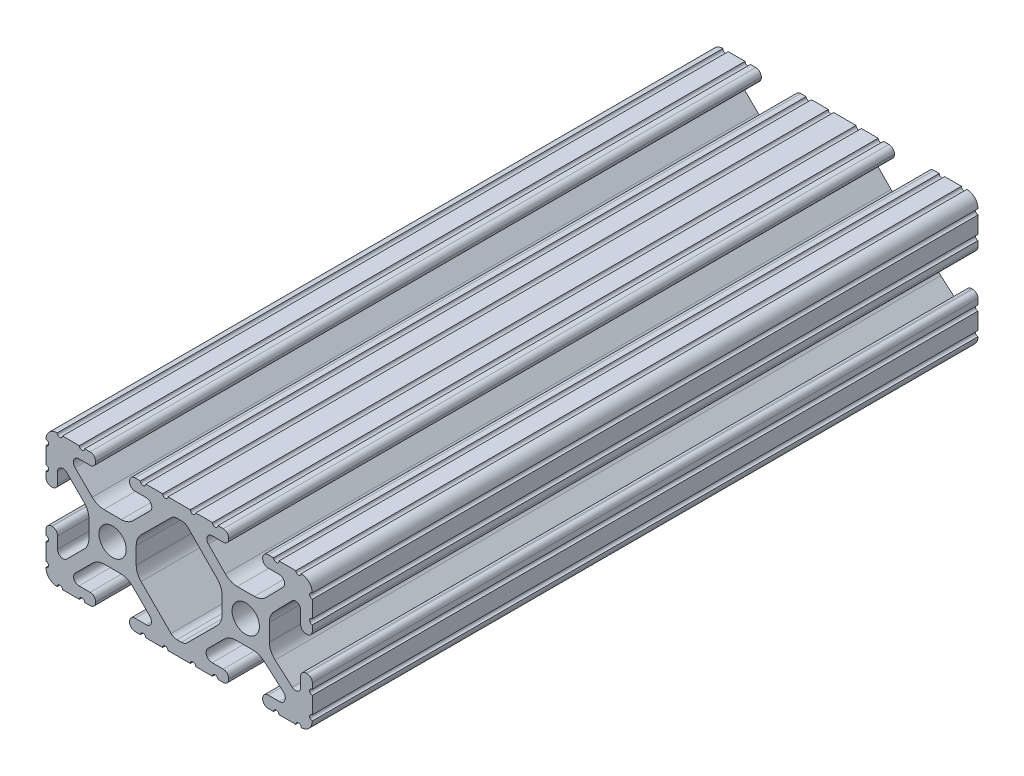
from build123d import *

# Parameters (mm, degrees)
SKETCH1_R      = 2.6035
EXTRUDE1_DEPTH = 127


with BuildPart() as part:
    # Sketch1 → Extrude1 (new body)
    with BuildSketch(Plane.XY):
        with BuildLine():
            Line((22.2504, 12.7), (19.03310265, 12.7))
            ThreePointArc((19.03310265, 12.7), (18.52510265, 12.192), (18.01710265, 12.7))
            Line((18.01710265, 12.7), (16.98745015, 12.7))
            ThreePointArc((16.98745015, 12.7), (16.245730386, 12.392769614), (15.9385, 11.65104985))
            Line((15.9385, 11.65104985), (15.9385, 11.53922))
            ThreePointArc((15.9385, 11.53922), (16.245750844, 10.797450844), (16.98752, 10.4902))
            Line((16.98752, 10.4902), (19.116384363, 10.4902))
            ThreePointArc((19.116384363, 10.4902), (20.052502933, 9.869096983), (19.844087081, 8.765172272))
            Line((19.844087081, 8.765172272), (16.618993479, 5.455112286))
            ThreePointArc((16.618993479, 5.455112286), (15.578994274, 4.745442459), (14.344932584, 4.4958))
            Line((14.344932584, 4.4958), (11.083317835, 4.4958))
            ThreePointArc((11.083317835, 4.4958), (9.854330953, 4.743306833), (8.816955189, 5.447238587))
            Line((8.816955189, 5.447238587), (5.564154119, 8.762652677))
            ThreePointArc((5.564154119, 8.762652677), (5.352591412, 9.867473037), (6.289393385, 10.4902))
            Line((6.289393385, 10.4902), (8.41248, 10.4902))
            ThreePointArc((8.41248, 10.4902), (9.154249156, 10.797450844), (9.4615, 11.53922))
            Line((9.4615, 11.53922), (9.4615, 11.65104985))
            ThreePointArc((9.4615, 11.65104985), (9.154269614, 12.392769614), (8.41254985, 12.7))
            Line((8.41254985, 12.7), (7.38288465, 12.7))
            ThreePointArc((7.38288465, 12.7), (6.87488465, 12.192), (6.36688465, 12.7))
            Line((6.36688465, 12.7), (3.14958095, 12.7))
            ThreePointArc((3.14958095, 12.7), (2.64158095, 12.192), (2.13358095, 12.7))
            Line((2.13358095, 12.7), (-2.13358095, 12.7))
            ThreePointArc((-2.13358095, 12.7), (-2.64158095, 12.192), (-3.14958095, 12.7))
            Line((-3.14958095, 12.7), (-6.36689735, 12.7))
            ThreePointArc((-6.36689735, 12.7), (-6.87489735, 12.192), (-7.38289735, 12.7))
            Line((-7.38289735, 12.7), (-8.41254985, 12.7))
            ThreePointArc((-8.41254985, 12.7), (-9.154269614, 12.392769614), (-9.4615, 11.65104985))
            Line((-9.4615, 11.65104985), (-9.4615, 11.53922))
            ThreePointArc((-9.4615, 11.53922), (-9.154249156, 10.797450844), (-8.41248, 10.4902))
            Line((-8.41248, 10.4902), (-6.283641037, 10.4902))
            ThreePointArc((-6.283641037, 10.4902), (-5.297291557, 9.829633109), (-5.532576693, 8.666071843))
            Line((-5.532576693, 8.666071843), (-8.809985098, 5.416263103))
            ThreePointArc((-8.809985098, 5.416263103), (-9.836720513, 4.734920264), (-11.045536121, 4.4958))
            Line((-11.045536121, 4.4958), (-14.354463879, 4.4958))
            ThreePointArc((-14.354463879, 4.4958), (-15.563279487, 4.734920264), (-16.590014902, 5.416263103))
            Line((-16.590014902, 5.416263103), (-19.867423307, 8.666071843))
            ThreePointArc((-19.867423307, 8.666071843), (-20.102708443, 9.829633109), (-19.116358963, 10.4902))
            Line((-19.116358963, 10.4902), (-16.98752, 10.4902))
            ThreePointArc((-16.98752, 10.4902), (-16.245750844, 10.797450844), (-15.9385, 11.53922))
            Line((-15.9385, 11.53922), (-15.9385, 11.65104985))
            ThreePointArc((-15.9385, 11.65104985), (-16.245730386, 12.392769614), (-16.98745015, 12.7))
            Line((-16.98745015, 12.7), (-18.01711535, 12.7))
            ThreePointArc((-18.01711535, 12.7), (-18.52511535, 12.192), (-19.03311535, 12.7))
            Line((-19.03311535, 12.7), (-22.2504, 12.7))
            ThreePointArc((-22.2504, 12.7), (-22.758323491, 12.192000006), (-23.266399977, 12.699846982))
            ThreePointArc((-23.266399977, 12.699846982), (-24.782522516, 12.082522516), (-25.399846982, 10.566399977))
            ThreePointArc((-25.399846982, 10.566399977), (-24.892000006, 10.058323491), (-25.4, 9.5504))
            Line((-25.4, 9.5504), (-25.4, 6.3330836))
            ThreePointArc((-25.4, 6.3330836), (-24.892, 5.8250836), (-25.4, 5.3170836))
            Line((-25.4, 5.3170836), (-25.4, 4.237520184))
            ThreePointArc((-25.4, 4.237520184), (-25.107393763, 3.531106237), (-24.400979816, 3.2385))
            Line((-24.400979816, 3.2385), (-24.23922, 3.2385))
            ThreePointArc((-24.23922, 3.2385), (-23.497450844, 3.545750844), (-23.1902, 4.28752))
            Line((-23.1902, 4.28752), (-23.1902, 6.334741132))
            ThreePointArc((-23.1902, 6.334741132), (-22.556026952, 7.286023527), (-21.434002553, 7.066535717))
            Line((-21.434002553, 7.066535717), (-18.147950853, 3.808156468))
            ThreePointArc((-18.147950853, 3.808156468), (-17.452759693, 2.774838327), (-17.208501877, 1.553619571))
            Line((-17.208501877, 1.553619571), (-17.208501877, -1.695179196))
            ThreePointArc((-17.208501877, -1.695179196), (-17.450738657, -2.911536421), (-18.140486065, -3.942289578))
            Line((-18.140486065, -3.942289578), (-21.431579576, -7.227386226))
            ThreePointArc((-21.431579576, -7.227386226), (-22.55444896, -7.449940594), (-23.1902, -6.498002195))
            Line((-23.1902, -6.498002195), (-23.1902, -4.28752))
            ThreePointArc((-23.1902, -4.28752), (-23.497450844, -3.545750844), (-24.23922, -3.2385))
            Line((-24.23922, -3.2385), (-24.35098, -3.2385))
            ThreePointArc((-24.35098, -3.2385), (-25.092749156, -3.545750844), (-25.4, -4.28752))
            Line((-25.4, -4.28752), (-25.4, -5.3171344))
            ThreePointArc((-25.4, -5.3171344), (-24.892, -5.8251344), (-25.4, -6.3331344))
            Line((-25.4, -6.3331344), (-25.4, -9.5504))
            ThreePointArc((-25.4, -9.5504), (-24.892000006, -10.058323491), (-25.399846982, -10.566399977))
            ThreePointArc((-25.399846982, -10.566399977), (-24.782522516, -12.082522516), (-23.266399977, -12.699846982))
            ThreePointArc((-23.266399977, -12.699846982), (-22.758323491, -12.192000006), (-22.2504, -12.7))
            Line((-22.2504, -12.7), (-19.03308995, -12.7))
            ThreePointArc((-19.03308995, -12.7), (-18.52508995, -12.192), (-18.01708995, -12.7))
            Line((-18.01708995, -12.7), (-16.9874692, -12.7))
            ThreePointArc((-16.9874692, -12.7), (-16.245700044, -12.392749156), (-15.9384492, -11.65098))
            Line((-15.9384492, -11.65098), (-15.9384492, -11.53922))
            ThreePointArc((-15.9384492, -11.53922), (-16.245700044, -10.797450844), (-16.9874692, -10.4902))
            Line((-16.9874692, -10.4902), (-19.116358963, -10.4902))
            ThreePointArc((-19.116358963, -10.4902), (-20.055197748, -9.862578342), (-19.834124023, -8.755124678))
            Line((-19.834124023, -8.755124678), (-16.49660751, -5.423689618))
            ThreePointArc((-16.49660751, -5.423689618), (-15.467274017, -4.736928798), (-14.253591699, -4.4958))
            Line((-14.253591699, -4.4958), (-11.146408301, -4.4958))
            ThreePointArc((-11.146408301, -4.4958), (-9.932725983, -4.736928798), (-8.90339249, -5.423689618))
            Line((-8.90339249, -5.423689618), (-5.565875977, -8.755124678))
            ThreePointArc((-5.565875977, -8.755124678), (-5.344802252, -9.862578342), (-6.283641037, -10.4902))
            Line((-6.283641037, -10.4902), (-8.4125308, -10.4902))
            ThreePointArc((-8.4125308, -10.4902), (-9.154299956, -10.797450844), (-9.4615508, -11.53922))
            Line((-9.4615508, -11.53922), (-9.4615508, -11.65098))
            ThreePointArc((-9.4615508, -11.65098), (-9.154299956, -12.392749156), (-8.4125308, -12.7))
            Line((-8.4125308, -12.7), (-7.38287195, -12.7))
            ThreePointArc((-7.38287195, -12.7), (-6.87487195, -12.192), (-6.36687195, -12.7))
            Line((-6.36687195, -12.7), (-3.14960635, -12.7))
            ThreePointArc((-3.14960635, -12.7), (-2.64160635, -12.192), (-2.13360635, -12.7))
            Line((-2.13360635, -12.7), (2.13360635, -12.7))
            ThreePointArc((2.13360635, -12.7), (2.64159365, -12.1920127), (3.14958095, -12.7))
            Line((3.14958095, -12.7), (6.36691005, -12.7))
            ThreePointArc((6.36691005, -12.7), (6.87491005, -12.192), (7.38291005, -12.7))
            Line((7.38291005, -12.7), (8.4125308, -12.7))
            ThreePointArc((8.4125308, -12.7), (9.154299956, -12.392749156), (9.4615508, -11.65098))
            Line((9.4615508, -11.65098), (9.4615508, -11.53922))
            ThreePointArc((9.4615508, -11.53922), (9.154299956, -10.797450844), (8.4125308, -10.4902))
            Line((8.4125308, -10.4902), (6.289393385, -10.4902))
            ThreePointArc((6.289393385, -10.4902), (5.231590322, -9.783049717), (5.480677245, -8.535265862))
            Line((5.480677245, -8.535265862), (8.597933595, -5.423689618))
            ThreePointArc((8.597933595, -5.423689618), (9.627267088, -4.736928798), (10.840949406, -4.4958))
            Line((10.840949406, -4.4958), (14.102564155, -4.4958))
            ThreePointArc((14.102564155, -4.4958), (15.215927525, -4.697410182), (16.187895372, -5.276636531))
            Line((16.187895372, -5.276636531), (19.868247549, -8.482246082))
            ThreePointArc((19.868247549, -8.482246082), (20.188435806, -9.746879864), (19.116384363, -10.4902))
            Line((19.116384363, -10.4902), (16.9874692, -10.4902))
            ThreePointArc((16.9874692, -10.4902), (16.245700044, -10.797450844), (15.9384492, -11.53922))
            Line((15.9384492, -11.53922), (15.9384492, -11.65098))
            ThreePointArc((15.9384492, -11.65098), (16.245700044, -12.392749156), (16.9874692, -12.7))
            Line((16.9874692, -12.7), (18.01710265, -12.7))
            ThreePointArc((18.01710265, -12.7), (18.52510265, -12.192), (19.03310265, -12.7))
            Line((19.03310265, -12.7), (22.2504, -12.7))
            ThreePointArc((22.2504, -12.7), (22.758323491, -12.192000006), (23.266399977, -12.699846982))
            ThreePointArc((23.266399977, -12.699846982), (24.782522516, -12.082522516), (25.399846982, -10.566399977))
            ThreePointArc((25.399846982, -10.566399977), (24.892000006, -10.058323492), (25.4, -9.550400001))
            Line((25.4, -9.550400001), (25.4, -6.333083592))
            ThreePointArc((25.4, -6.333083592), (24.892000001, -5.825083593), (25.4, -5.317083593))
            Line((25.4, -5.317083593), (25.4, -4.237520184))
            ThreePointArc((25.4, -4.237520184), (25.107393763, -3.531106237), (24.400979816, -3.2385))
            Line((24.400979816, -3.2385), (24.189220184, -3.2385))
            ThreePointArc((24.189220184, -3.2385), (23.482806237, -3.531106237), (23.1902, -4.237520184))
            Line((23.1902, -4.237520184), (23.1902, -6.155876159))
            ThreePointArc((23.1902, -6.155876159), (22.62232736, -7.038258539), (21.583974541, -6.886926384))
            Line((21.583974541, -6.886926384), (18.29817066, -4.024970844))
            ThreePointArc((18.29817066, -4.024970844), (17.493730985, -2.946044689), (17.208501877, -1.630807374))
            Line((17.208501877, -1.630807374), (17.208501877, 1.630807374))
            ThreePointArc((17.208501877, 1.630807374), (17.442348332, 2.82673414), (18.109440981, 3.846495088))
            Line((18.109440981, 3.846495088), (21.526346532, 7.353420386))
            ThreePointArc((21.526346532, 7.353420386), (22.585896263, 7.574939077), (23.1902, 6.676867167))
            Line((23.1902, 6.676867167), (23.1902, 4.237520184))
            ThreePointArc((23.1902, 4.237520184), (23.482806237, 3.531106237), (24.189220184, 3.2385))
            Line((24.189220184, 3.2385), (24.400979816, 3.2385))
            ThreePointArc((24.400979816, 3.2385), (25.107393763, 3.531106237), (25.4, 4.237520184))
            Line((25.4, 4.237520184), (25.4, 5.3170836))
            ThreePointArc((25.4, 5.3170836), (24.891949193, 5.825134407), (25.4, 6.333185215))
            Line((25.4, 6.333185215), (25.4, 9.550400015))
            ThreePointArc((25.4, 9.550400015), (24.892000013, 10.058323498), (25.399846982, 10.566399977))
            ThreePointArc((25.399846982, 10.566399977), (24.782522516, 12.082522516), (23.266399977, 12.699846982))
            ThreePointArc((23.266399977, 12.699846982), (22.758323491, 12.192000006), (22.2504, 12.7))
        make_face()
        with Locations((-12.7, 0)):
            Circle(SKETCH1_R, mode=Mode.SUBTRACT)
        with Locations((12.7, 0)):
            Circle(SKETCH1_R, mode=Mode.SUBTRACT)
        with BuildLine():
            Line((-7.259513935, -3.869413038), (-1.545748891, -9.572766749))
            ThreePointArc((-1.545748891, -9.572766749), (-1.035199478, -9.913400116), (-0.433213048, -10.033))
            Line((-0.433213048, -10.033), (0.433213048, -10.033))
            ThreePointArc((0.433213048, -10.033), (1.035199478, -9.913400116), (1.545748891, -9.572766749))
            Line((1.545748891, -9.572766749), (7.259513935, -3.869413038))
            ThreePointArc((7.259513935, -3.869413038), (7.949261343, -2.838659881), (8.191498123, -1.622302656))
            Line((8.191498123, -1.622302656), (8.191498123, 1.622302656))
            ThreePointArc((8.191498123, 1.622302656), (7.955573352, 2.823327967), (7.282860769, 3.845864069))
            Line((7.282860769, 3.845864069), (1.675572808, 9.561086461))
            ThreePointArc((1.675572808, 9.561086461), (1.161034429, 9.910236611), (0.551456936, 10.033))
            Line((0.551456936, 10.033), (-0.395199982, 10.033))
            ThreePointArc((-0.395199982, 10.033), (-0.994772524, 9.914396349), (-1.50403329, 9.576450301))
            Line((-1.50403329, 9.576450301), (-7.252049147, 3.876839553))
            ThreePointArc((-7.252049147, 3.876839553), (-7.947240307, 2.843521412), (-8.191498123, 1.622302656))
            Line((-8.191498123, 1.622302656), (-8.191498123, -1.622302656))
            ThreePointArc((-8.191498123, -1.622302656), (-7.949261343, -2.838659881), (-7.259513935, -3.869413038))
        make_face(mode=Mode.SUBTRACT)
    extrude(amount=-EXTRUDE1_DEPTH)


solid = part.part
